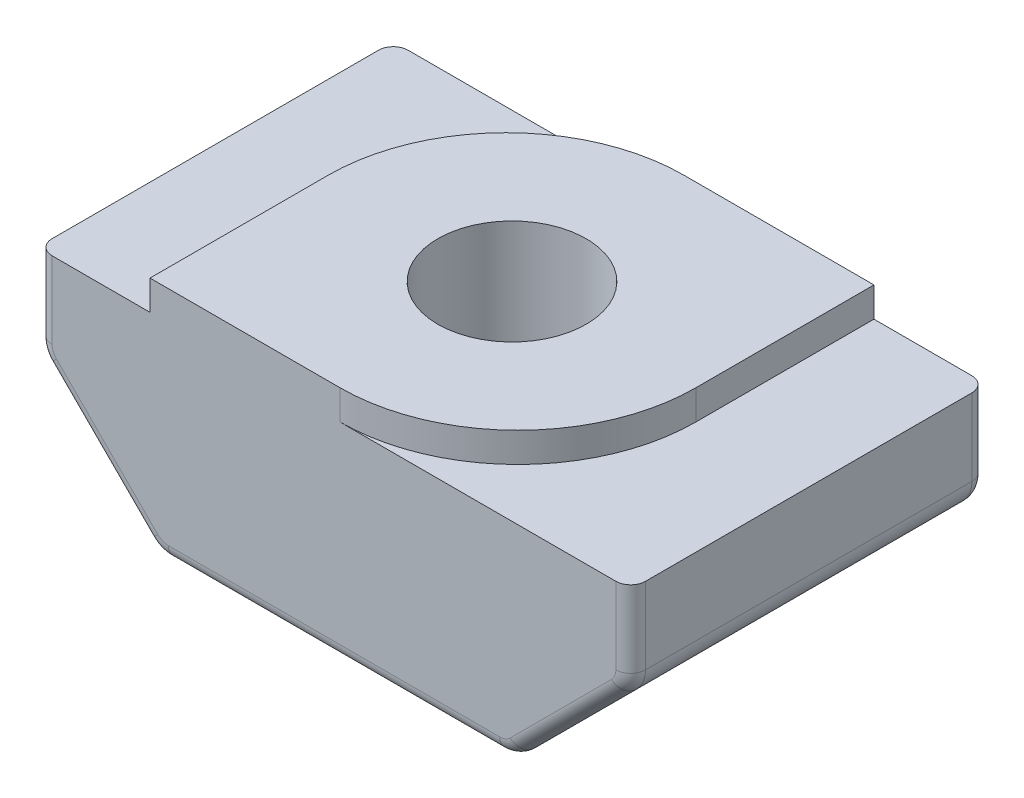
from build123d import *

# Parameters (mm, degrees)
BOSS_EXTRUDE1_DEPTH = 6
M3_TAPPED_HOLE1_D   = 2.5
FILLET1_R           = 3
FILLET2_R           = 0.5
FILLET3_R           = 0.25


with BuildPart() as part:
    # Sketch1 → Boss-Extrude1 (new body)
    with BuildSketch(Plane.XY):
        Polygon((3.1, 0), (-3.1, 0), (-3.1, -0.5), (-5, -0.5), (-5, -2), (-3, -4), (3, -4), (5, -2), (5, -0.5), (3.1, -0.5), align=None)
    extrude(amount=BOSS_EXTRUDE1_DEPTH)

    # M3 Tapped Hole1 (through all)
    with Locations(Plane(origin=(0, 0, 0), x_dir=(-1, 0, 0), z_dir=(0, 1, 0))):
        with Locations((0, 3)):
            Hole(M3_TAPPED_HOLE1_D / 2)

    # Fillet1
    fillet1_edges = [part.edges().sort_by_distance(p)[0] for p in [
        (-3.1, -0.25, 0),
        (3.1, -0.25, 6),
    ]]
    fillet(fillet1_edges, radius=FILLET1_R)

    # Fillet2
    fillet2_edges = [part.edges().sort_by_distance(p)[0] for p in [
        (5, -2, 3),
        (3, -4, 3),
        (-3, -4, 3),
        (-5, -2, 3),
    ]]
    fillet(fillet2_edges, radius=FILLET2_R)

    # Fillet3
    fillet3_edges = [part.edges().sort_by_distance(p)[0] for p in [
        (-5, -1.146446609, 6),
        (-5, -1.146446609, 0),
        (5, -1.146446609, 0),
        (5, -1.146446609, 6),
        (4, -3, 0),
        (0, -4, 0),
        (-4, -3, 0),
        (-2.984234935, -3.961939766, 0),
        (-4.961939766, -1.984234935, 0),
        (2.984234935, -3.961939766, 0),
        (4.961939766, -1.984234935, 0),
        (4, -3, 6),
        (-4, -3, 6),
        (0, -4, 6),
        (-2.984234935, -3.961939766, 6),
        (-4.961939766, -1.984234935, 6),
        (2.984234935, -3.961939766, 6),
        (4.961939766, -1.984234935, 6),
    ]]
    fillet(fillet3_edges, radius=FILLET3_R)


solid = part.part
